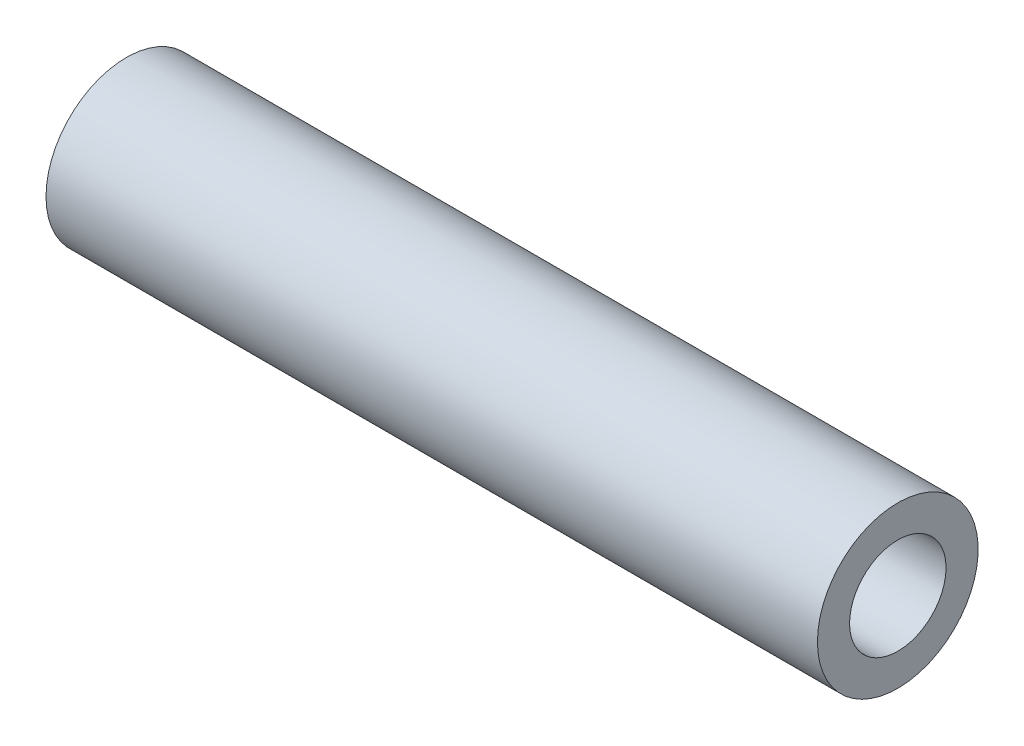
from build123d import *

# Parameters (mm, degrees)
SKETCH1_W = 203.2
SKETCH1_H = 8.466666667


with BuildPart() as part:
    # Sketch1 → Revolve1 (revolve)
    with BuildSketch(Plane.XY):
        with Locations((101.6, 16.933333334)):
            Rectangle(SKETCH1_W, SKETCH1_H)
    revolve(axis=Axis((0, 0, 0), (1, 0, 0)))


solid = part.part
